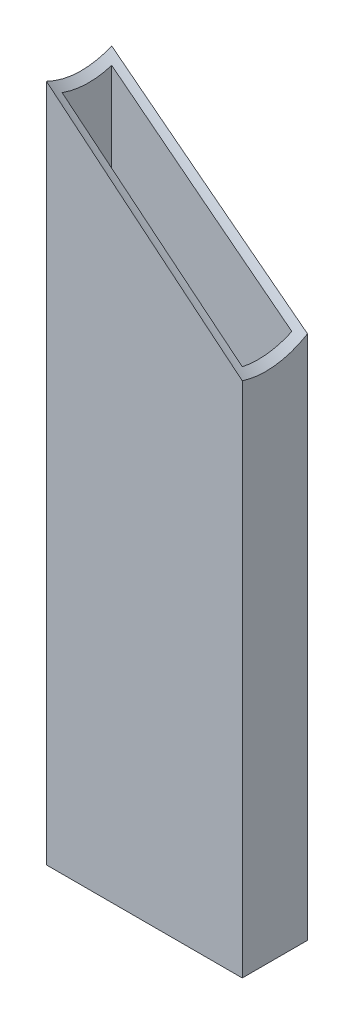
from build123d import *

# Parameters (mm, degrees)
SKETCH1_W           = 76.2
SKETCH1_H           = 25.4
SKETCH1_W_2         = 70.104
SKETCH1_H_2         = 19.304
BOSS_EXTRUDE1_DEPTH = 241.091915
SKETCH3_W           = 76.2
SKETCH3_H           = 25.4
SKETCH3_W_2         = 70.104
SKETCH3_H_2         = 19.304
BOSS_EXTRUDE2_DEPTH = 3.048
SKETCH4_W           = 76.2
SKETCH4_H           = 25.4
SKETCH4_W_2         = 70.104
SKETCH4_H_2         = 19.304
BOSS_EXTRUDE3_DEPTH = 38.1
CUT_EXTRUDE2_START  = 105.580594
SKETCH5_R           = 38.1
CUT_EXTRUDE2_DEPTH  = 111.6566


with BuildPart() as part:
    # Sketch1 → Boss-Extrude1 (new body)
    with BuildSketch(Plane(origin=(0, 0, 0), x_dir=(1, 0, 0), z_dir=(0, 1, 0))):
        Rectangle(SKETCH1_W, SKETCH1_H)
        Rectangle(SKETCH1_W_2, SKETCH1_H_2, mode=Mode.SUBTRACT)
    extrude(amount=BOSS_EXTRUDE1_DEPTH)

    # Sketch3 → Boss-Extrude2 (add)
    with BuildSketch(Plane(origin=(0, 241.09191526, 0), x_dir=(1, 0, 0), z_dir=(0, 1, 0))):
        Rectangle(SKETCH3_W, SKETCH3_H)
        Rectangle(SKETCH3_W_2, SKETCH3_H_2, mode=Mode.SUBTRACT)
    extrude(amount=BOSS_EXTRUDE2_DEPTH)

    # Sketch4 → Boss-Extrude3 (add)
    with BuildSketch(Plane.XZ):
        Rectangle(SKETCH4_W, SKETCH4_H)
        Rectangle(SKETCH4_W_2, SKETCH4_H_2, mode=Mode.SUBTRACT)
    extrude(amount=BOSS_EXTRUDE3_DEPTH)

    # Sketch5 → Cut-Extrude2 (cut)
    with BuildSketch(Plane(origin=(-107.386524849, 327.150922863, -6.145385199), x_dir=(0.03097261, -0.032688156, -0.998985576), z_dir=(0.779560672, -0.624735905, 0.044611748)).offset(CUT_EXTRUDE2_START)):
        Circle(SKETCH5_R)
    extrude(amount=CUT_EXTRUDE2_DEPTH, mode=Mode.SUBTRACT)


solid = part.part
